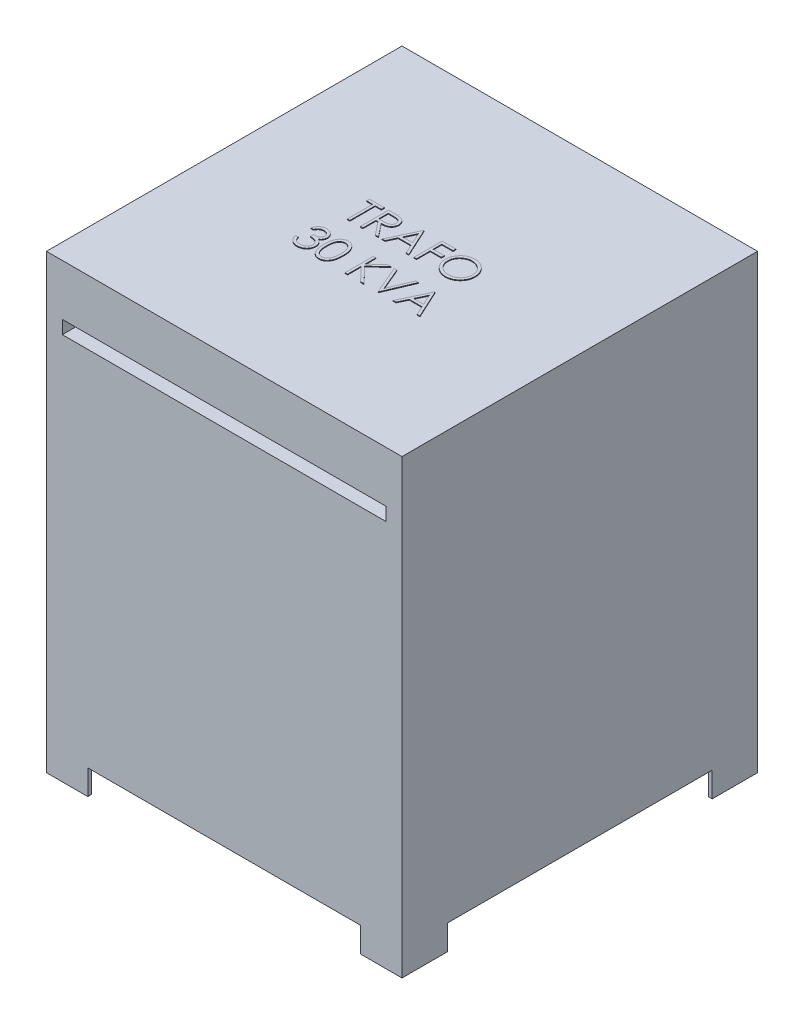
from build123d import *

# Parameters (mm, degrees)
CROQUIS1_W              = 500
CROQUIS1_H              = 500
SALIENTE_EXTRUIR1_DEPTH = 600
CROQUIS2_W              = 455.22672881
CROQUIS2_H              = 18.63501229
CORTAR_EXTRUIR1_DEPTH   = 20
SALIENTE_EXTRUIR2_DEPTH = 35
SALIENTE_EXTRUIR3_DEPTH = 1


with BuildPart() as part:
    # Croquis1 → Saliente-Extruir1 (new body)
    with BuildSketch(Plane(origin=(0, 0, 0), x_dir=(1, 0, 0), z_dir=(0, 1, 0))):
        with Locations((250, -250)):
            Rectangle(CROQUIS1_W, CROQUIS1_H)
    extrude(amount=SALIENTE_EXTRUIR1_DEPTH)

    # Croquis2 → Cortar-Extruir1 (cut)
    with BuildSketch(Plane.XY.offset(500)):
        with Locations((250, 518.961394413)):
            Rectangle(CROQUIS2_W, CROQUIS2_H)
    extrude(amount=-CORTAR_EXTRUIR1_DEPTH, mode=Mode.SUBTRACT)

    # Croquis3 → Saliente-Extruir2 (add)
    with BuildSketch(Plane.XZ):
        Polygon((500, 0), (500, 63.833187034), (495, 63.833187034), (495, 5), (441.775770603, 5), (441.775770603, 0), align=None)
        Polygon((58.224229397, 5), (58.224229397, 0), (0, 0), (0, 63.833187034), (5, 63.833187034), (5, 5), align=None)
        Polygon((441.775770603, 495), (441.775770603, 500), (500, 500), (500, 436.166812966), (495, 436.166812966), (495, 495), align=None)
        Polygon((0, 500), (0, 436.166812966), (5, 436.166812966), (5, 495), (58.224229397, 495), (58.224229397, 500), align=None)
    extrude(amount=SALIENTE_EXTRUIR2_DEPTH)

    # Croquis4 → Saliente-Extruir3 (add)
    with BuildSketch(Plane(origin=(0, 600, 0), x_dir=(1, 0, 0), z_dir=(0, 1, 0))):
        Polygon((164.519230769, -214.383012821), (164.519230769, -210.3125), (185.380608974, -210.3125), (185.380608974, -214.383012821), (176.730769231, -214.383012821), (176.730769231, -250), (173.169070513, -250), (173.169070513, -214.383012821), align=None)
        with BuildLine():
            Line((191.486378205, -210.3125), (199.428648337, -210.3125))
            add(Edge.make_bspline(
                [(199.428648337, -210.3125), (199.958659348, -210.314264234), (200.9763392, -210.317651759), (202.434268248, -210.33654032), (203.75900408, -210.390678104), (204.949854044, -210.437266506), (206.006796292, -210.522219769), (206.933071821, -210.603416392), (207.724414462, -210.70970701), (208.20345224, -210.808420288), (208.420347556, -210.853114984)],
                knots=[0, 0, 0, 0, 0.001590064, 0.003053099, 0.004373697, 0.005567528, 0.006627892, 0.007554255, 0.00835703, 0.009021242, 0.009021242, 0.009021242, 0.009021242], degree=3))
            add(Edge.make_bspline(
                [(208.420347556, -210.853114984), (208.710708383, -210.924855984), (209.285235853, -211.066807554), (210.112437495, -211.366840528), (210.900680275, -211.7140452), (211.646689891, -212.1218481), (212.346729666, -212.593276405), (213.008017654, -213.120191722), (213.633554605, -213.69971093), (214.198042733, -214.346445294), (214.730298051, -215.024948573), (215.179204798, -215.758642959), (215.566174702, -216.525876351), (215.874268957, -217.334451535), (216.122349549, -218.176526983), (216.297272085, -219.059730303), (216.402173945, -219.980037789), (216.412853914, -220.607756933), (216.418269231, -220.926044171)],
                knots=[0, 0, 0, 0, 0.00089672, 0.001774311, 0.002635617, 0.003478865, 0.004321176, 0.005164237, 0.006013572, 0.006875172, 0.007737029, 0.008597454, 0.009450761, 0.010311517, 0.01118954, 0.012081383, 0.013009382, 0.013963938, 0.013963938, 0.013963938, 0.013963938], degree=3))
            add(Edge.make_bspline(
                [(216.418269231, -220.926044171), (216.401611842, -221.454852946), (216.369108961, -222.486695832), (216.066065374, -223.984171898), (215.56967091, -225.381050734), (214.8856479, -226.675573503), (214.014569917, -227.842506714), (212.967672732, -228.867469912), (211.744372316, -229.725172492), (210.605575608, -230.319949832), (209.599619951, -230.70086942), (208.771474351, -230.968888847), (207.868107731, -231.175966489), (206.898175455, -231.361478697), (205.857641147, -231.501538089), (204.748998736, -231.604120009), (203.571457552, -231.668232882), (202.762523462, -231.677780616), (202.346379207, -231.682692308)],
                knots=[0, 0, 0, 0, 0.001584968, 0.003092683, 0.004561215, 0.006019382, 0.007467916, 0.008912779, 0.010395192, 0.011934848, 0.012752794, 0.013620243, 0.014543906, 0.015530919, 0.016582184, 0.017692087, 0.018870437, 0.020118849, 0.020118849, 0.020118849, 0.020118849], degree=3))
            Line((202.346379207, -231.682692308), (216.927083333, -250))
            Line((216.927083333, -250), (212.522661258, -250))
            Line((212.522661258, -250), (197.941957131, -231.682692308))
            Line((197.941957131, -231.682692308), (195.048076923, -231.682692308))
            Line((195.048076923, -231.682692308), (195.048076923, -250))
            Line((195.048076923, -250), (191.486378205, -250))
            Line((191.486378205, -250), (191.486378205, -210.3125))
        make_face()
        with BuildLine():
            Line((195.048076923, -214.383012821), (195.048076923, -227.612179487))
            Line((195.048076923, -227.612179487), (202.314578325, -227.66783103))
            add(Edge.make_bspline(
                [(202.314578325, -227.66783103), (202.653850195, -227.667981124), (203.311455709, -227.668272049), (204.262829319, -227.622985479), (205.148655585, -227.571467496), (205.965546257, -227.492666881), (206.713866263, -227.391111425), (207.393241574, -227.264077586), (208.00478118, -227.116076518), (208.718005678, -226.887004511), (209.514437775, -226.524079126), (210.379982008, -225.996059631), (211.117062087, -225.331927655), (211.739791419, -224.572496502), (212.240187651, -223.737514037), (212.592976124, -222.836989137), (212.816841318, -221.893655838), (212.84324536, -221.245296936), (212.856570513, -220.91809395)],
                knots=[0, 0, 0, 0, 0.001017659, 0.001972513, 0.002856741, 0.003679464, 0.004433898, 0.005121534, 0.005752062, 0.006320267, 0.007366438, 0.00837012, 0.009349902, 0.010327133, 0.011307463, 0.012256741, 0.013219111, 0.014199603, 0.014199603, 0.014199603, 0.014199603], degree=3))
            add(Edge.make_bspline(
                [(212.856570513, -220.91809395), (212.842939318, -220.598931909), (212.815927265, -219.966469202), (212.595392122, -219.040549505), (212.222450029, -218.166665339), (211.71986751, -217.348371625), (211.107555664, -216.60558337), (210.389576895, -215.970048688), (209.585562628, -215.445612794), (208.834094576, -215.110487229), (208.162420916, -214.905021036), (207.579245307, -214.760431947), (206.920302658, -214.644266987), (206.182393439, -214.551193439), (205.368667805, -214.471195411), (204.475011315, -214.417313635), (203.507353181, -214.385406426), (202.836669229, -214.383829257), (202.489483173, -214.383012821)],
                knots=[0, 0, 0, 0, 0.000956706, 0.001895842, 0.002836424, 0.003796329, 0.004767428, 0.005713537, 0.006661749, 0.007636875, 0.008169955, 0.008767704, 0.009438262, 0.010175878, 0.010998601, 0.011890763, 0.012861211, 0.01390272, 0.01390272, 0.01390272, 0.01390272], degree=3))
            Line((202.489483173, -214.383012821), (195.048076923, -214.383012821))
        make_face(mode=Mode.SUBTRACT)
        Polygon((241.350160256, -210.3125), (259.667467949, -250), (255.795710637, -250), (249.928448017, -237.279647436), (231.937099359, -237.279647436), (225.902882111, -250), (222.015224359, -250), (240.841346154, -210.3125), align=None)
        Polygon((241.056002103, -218.048064403), (233.869002905, -233.209134615), (248.052196014, -233.209134615), align=None, mode=Mode.SUBTRACT)
        Polygon((266.790865385, -210.3125), (286.125801282, -210.3125), (286.125801282, -214.383012821), (270.352564103, -214.383012821), (270.352564103, -226.594551282), (286.125801282, -226.594551282), (286.125801282, -230.665064103), (270.352564103, -230.665064103), (270.352564103, -250), (266.790865385, -250), align=None)
        with BuildLine():
            add(Edge.make_bspline(
                [(311.820913462, -209.294871795), (312.555791091, -209.313484998), (313.999151386, -209.350042866), (316.120447101, -209.629886272), (318.145587914, -210.114021498), (320.091070738, -210.758807103), (321.933625026, -211.618941651), (323.68711961, -212.658585744), (325.347382376, -213.888631303), (326.892035541, -215.299569858), (328.305556317, -216.834721522), (329.55090342, -218.472997824), (330.594597287, -220.204493172), (331.451686123, -222.024004376), (332.124090001, -223.927416513), (332.588082729, -225.92487708), (332.884470681, -228.003444012), (332.919121014, -229.421159353), (332.936698718, -230.140349559)],
                knots=[0, 0, 0, 0, 0.002204277, 0.004329381, 0.006404312, 0.008443246, 0.010467197, 0.012491945, 0.014549502, 0.016654434, 0.018758856, 0.020802078, 0.022817267, 0.024812408, 0.026826452, 0.028860869, 0.030955522, 0.033112143, 0.033112143, 0.033112143, 0.033112143], degree=3))
            add(Edge.make_bspline(
                [(332.936698718, -230.140349559), (332.91912359, -230.854242031), (332.884480977, -232.261406799), (332.587745732, -234.326783353), (332.122370107, -236.312186787), (331.457930303, -238.214302671), (330.60492711, -240.035137546), (329.554283652, -241.769900326), (328.31670028, -243.419159727), (326.908283308, -244.964847985), (325.372932207, -246.382230019), (323.726124717, -247.61729227), (322.004896893, -248.680056897), (320.18709931, -249.528050343), (318.296839963, -250.205821226), (316.317201121, -250.667926942), (314.257458946, -250.966003236), (312.852850242, -251.000231051), (312.138922276, -251.017628205)],
                knots=[0, 0, 0, 0, 0.002140736, 0.004219639, 0.006246322, 0.008250234, 0.01025257, 0.012267758, 0.014323686, 0.016428619, 0.018533041, 0.02058261, 0.022595131, 0.024590272, 0.026589321, 0.028608271, 0.030679299, 0.032820035, 0.032820035, 0.032820035, 0.032820035], degree=3))
            add(Edge.make_bspline(
                [(312.138922276, -251.017628205), (311.419735801, -251.000059265), (310.002027817, -250.965426207), (307.920848934, -250.668547778), (305.921985231, -250.204302636), (304.011152856, -249.540847422), (302.187286244, -248.683402038), (300.446818342, -247.637870239), (298.796735154, -246.397271406), (297.250717136, -244.989311141), (295.836150335, -243.456562292), (294.6028967, -241.814245293), (293.55712979, -240.09458074), (292.702563431, -238.292796315), (292.026011079, -236.417602277), (291.564447516, -234.456490077), (291.265816631, -232.420640323), (291.23140364, -231.034493173), (291.213942308, -230.331154848)],
                knots=[0, 0, 0, 0, 0.002156621, 0.004251274, 0.006293428, 0.00830485, 0.010307185, 0.012329184, 0.014385112, 0.016490044, 0.018594466, 0.020632903, 0.02264129, 0.02462206, 0.02660613, 0.028609617, 0.030657027, 0.032765994, 0.032765994, 0.032765994, 0.032765994], degree=3))
            add(Edge.make_bspline(
                [(291.213942308, -230.331154848), (291.220004692, -229.859070117), (291.232052982, -228.920856217), (291.377101638, -227.527636733), (291.587578071, -226.156823024), (291.889224758, -224.812313168), (292.283737411, -223.497398431), (292.749238078, -222.203010316), (293.317788111, -220.942266306), (293.960506173, -219.709193918), (294.677849889, -218.523014986), (295.470190977, -217.401791141), (296.309699173, -216.336113767), (297.230034083, -215.353598634), (298.200863416, -214.425663423), (299.237936097, -213.566568328), (300.334924047, -212.768566652), (301.49654746, -212.049425285), (302.694183255, -211.399013669), (303.928768146, -210.840873037), (305.183534627, -210.361832876), (306.464359652, -209.973566376), (307.767841979, -209.667042396), (309.0968265, -209.458316153), (310.450254459, -209.312897548), (311.362061379, -209.300906231), (311.820913462, -209.294871795)],
                knots=[0, 0, 0, 0, 0.001415697, 0.002813535, 0.004197719, 0.005574852, 0.00694326, 0.008313953, 0.009698342, 0.011088744, 0.012483572, 0.013853272, 0.015205394, 0.016549922, 0.017888301, 0.019231959, 0.020586859, 0.021954598, 0.023327663, 0.024672543, 0.026016201, 0.027354155, 0.02868479, 0.030029717, 0.031387996, 0.032763958, 0.032763958, 0.032763958, 0.032763958], degree=3))
        make_face()
        with BuildLine():
            add(Edge.make_bspline(
                [(311.995818309, -213.365384615), (311.61918809, -213.369975782), (310.869528261, -213.379114222), (309.755051823, -213.499488854), (308.655232573, -213.671050988), (307.569843377, -213.915770018), (306.503425632, -214.249190974), (305.44603904, -214.632922701), (304.40732584, -215.100340424), (303.39071513, -215.628441626), (302.40516026, -216.212969567), (301.475194806, -216.858988711), (300.598411254, -217.551349103), (299.776956355, -218.291666545), (299.013242171, -219.083711136), (298.292237074, -219.915475367), (297.642840925, -220.810733417), (297.047691973, -221.745208567), (296.515110213, -222.717683639), (296.041520923, -223.71792047), (295.654125466, -224.754078169), (295.338186021, -225.814915491), (295.076250666, -226.898752311), (294.910312419, -228.013810597), (294.788615129, -229.154487313), (294.779999024, -229.92535298), (294.775641026, -230.315254407)],
                knots=[0, 0, 0, 0, 0.001129379, 0.002247961, 0.003358946, 0.004467909, 0.00558199, 0.006708848, 0.007840575, 0.008996232, 0.010144261, 0.011275598, 0.012390586, 0.013493863, 0.014590216, 0.015689677, 0.016793241, 0.017904823, 0.019011389, 0.020117499, 0.021222007, 0.022326173, 0.02343693, 0.024563619, 0.025705936, 0.026875051, 0.026875051, 0.026875051, 0.026875051], degree=3))
            add(Edge.make_bspline(
                [(294.775641026, -230.315254407), (294.79009705, -230.888593875), (294.818536521, -232.016529977), (295.067519682, -233.669436609), (295.451036714, -235.257937713), (296.016383637, -236.773341506), (296.723395071, -238.228673998), (297.596824987, -239.611024828), (298.631637833, -240.9207676), (299.807108179, -242.148758597), (301.092106727, -243.269599413), (302.456593932, -244.253434493), (303.885951803, -245.08585429), (305.383907762, -245.764001093), (306.942464678, -246.30136687), (308.57166548, -246.669651347), (310.260657299, -246.912033743), (311.411942406, -246.935310529), (311.995818309, -246.947115385)],
                knots=[0, 0, 0, 0, 0.001719087, 0.003381976, 0.005003606, 0.006613403, 0.008224083, 0.009849704, 0.011508559, 0.013223615, 0.01494228, 0.016616929, 0.018262778, 0.019895847, 0.021542618, 0.023199204, 0.024900347, 0.026650858, 0.026650858, 0.026650858, 0.026650858], degree=3))
            add(Edge.make_bspline(
                [(311.995818309, -246.947115385), (312.388265337, -246.941723505), (313.16660566, -246.931029788), (314.324295958, -246.823321577), (315.461129787, -246.650603058), (316.575512604, -246.401925088), (317.666179661, -246.090693372), (318.737683232, -245.720945028), (319.778610274, -245.259649237), (320.802092364, -244.749971571), (321.781764033, -244.168944785), (322.716977658, -243.544851481), (323.584160644, -242.853510871), (324.405001007, -242.124192818), (325.171850695, -241.342192043), (325.879523998, -240.508525242), (326.525637997, -239.617930289), (327.120560954, -238.684872564), (327.651276523, -237.709736484), (328.113682378, -236.705873172), (328.50597762, -235.675754521), (328.822666916, -234.617894737), (329.070832419, -233.53430297), (329.241827939, -232.423528333), (329.361439699, -231.287792932), (329.370455306, -230.519625994), (329.375, -230.132399339)],
                knots=[0, 0, 0, 0, 0.001177062, 0.002334468, 0.003484725, 0.004624716, 0.005757169, 0.006886128, 0.008021925, 0.00917034, 0.010314315, 0.011436677, 0.012540499, 0.013638464, 0.014729123, 0.015823427, 0.016915881, 0.018027463, 0.019141004, 0.020243766, 0.021340839, 0.022445004, 0.023553967, 0.024672804, 0.025815121, 0.026976288, 0.026976288, 0.026976288, 0.026976288], degree=3))
            add(Edge.make_bspline(
                [(329.375, -230.132399339), (329.370451665, -229.747821746), (329.361429206, -228.984941248), (329.241885074, -227.857126612), (329.070651763, -226.75434466), (328.823878199, -225.680924751), (328.505809491, -224.636593262), (328.11361387, -223.622331033), (327.651137706, -222.634359535), (327.120365876, -221.675120632), (326.523740021, -220.754657085), (325.871796369, -219.874701157), (325.153278582, -219.051778108), (324.388715621, -218.265572203), (323.559010047, -217.53285149), (322.667920284, -216.853372908), (321.726264295, -216.210738458), (320.72923225, -215.631011105), (319.700260632, -215.095635431), (318.644414858, -214.636949949), (317.573656318, -214.247194666), (316.490707901, -213.914761223), (315.386454486, -213.672009453), (314.268357499, -213.499334245), (313.137963852, -213.379156119), (312.377741629, -213.369989684), (311.995818309, -213.365384615)],
                knots=[0, 0, 0, 0, 0.001153221, 0.002287625, 0.00339861, 0.004499823, 0.005588771, 0.006670994, 0.007759333, 0.008858938, 0.009957133, 0.011047908, 0.012141345, 0.013232004, 0.014335912, 0.015458555, 0.016591956, 0.017753668, 0.018916386, 0.020069936, 0.021204257, 0.022333552, 0.023465782, 0.024592471, 0.025726876, 0.026872149, 0.026872149, 0.026872149, 0.026872149], degree=3))
        make_face(mode=Mode.SUBTRACT)
        with BuildLine():
            Line((162.229567308, -286.616987179), (158.66786859, -286.616987179))
            add(Edge.make_bspline(
                [(158.66786859, -286.616987179), (158.764360816, -286.217475977), (158.952995227, -285.436464254), (159.346440926, -284.320596207), (159.77505748, -283.264641991), (160.289737505, -282.288374013), (160.851131415, -281.372172169), (161.494326561, -280.536816919), (162.189648415, -279.761062757), (162.958734893, -279.072618009), (163.76528311, -278.44920983), (164.620657816, -277.917680162), (165.507649557, -277.460433071), (166.432403832, -277.083739371), (167.397673815, -276.799967808), (168.394732937, -276.594082601), (169.426194054, -276.460379788), (170.126367626, -276.447330957), (170.481896034, -276.440705128)],
                knots=[0, 0, 0, 0, 0.001232182, 0.002408814, 0.003545696, 0.004648027, 0.005715757, 0.006765216, 0.007806452, 0.008836459, 0.009857312, 0.010860993, 0.01185302, 0.012848069, 0.01385172, 0.014866767, 0.015900204, 0.016966275, 0.016966275, 0.016966275, 0.016966275], degree=3))
            add(Edge.make_bspline(
                [(170.481896034, -276.440705128), (170.999905698, -276.456344614), (172.024625733, -276.487282443), (173.530063855, -276.769794357), (174.981796536, -277.216847197), (176.363933542, -277.834540353), (177.647749697, -278.596396493), (178.790026101, -279.503139492), (179.77527975, -280.537274428), (180.601849925, -281.679509756), (181.249039647, -282.900246335), (181.72626906, -284.156640975), (182.016800622, -285.445713329), (182.054453364, -286.316086048), (182.073317308, -286.752140925)],
                knots=[0, 0, 0, 0, 0.001552758, 0.003071645, 0.004577934, 0.006101164, 0.007602324, 0.009045087, 0.010462145, 0.011874334, 0.013261414, 0.014594825, 0.015896939, 0.01720426, 0.01720426, 0.01720426, 0.01720426], degree=3))
            add(Edge.make_bspline(
                [(182.073317308, -286.752140925), (182.060123016, -287.171771544), (182.034303836, -287.992923546), (181.815073424, -289.191729808), (181.446135444, -290.321594382), (180.935076529, -291.387273631), (180.273525021, -292.382010654), (179.472147119, -293.308043524), (178.525286579, -294.169479513), (177.807748622, -294.662959252), (177.438338842, -294.917017228)],
                knots=[0, 0, 0, 0, 0.001258171, 0.002462045, 0.003641173, 0.004814605, 0.005996491, 0.007214095, 0.008480478, 0.009824277, 0.009824277, 0.009824277, 0.009824277], degree=3))
            add(Edge.make_bspline(
                [(177.438338842, -294.917017228), (177.860520345, -295.120876851), (178.696984008, -295.524781728), (179.837155192, -296.316896121), (180.8721811, -297.231481488), (181.449392913, -297.945206213), (181.739408053, -298.303811098)],
                knots=[0, 0, 0, 0, 0.001404514, 0.002782748, 0.004150764, 0.005532205, 0.005532205, 0.005532205, 0.005532205], degree=3))
            add(Edge.make_bspline(
                [(181.739408053, -298.303811098), (181.930376846, -298.565269531), (182.309187185, -299.083904835), (182.776768684, -299.917755379), (183.200961319, -300.760848159), (183.531503985, -301.635780709), (183.78747551, -302.532412204), (183.97044659, -303.452282231), (184.084113188, -304.396141949), (184.100391322, -305.034685252), (184.108573718, -305.35565655)],
                knots=[0, 0, 0, 0, 0.000970448, 0.001925004, 0.002863669, 0.003799772, 0.004725827, 0.005658209, 0.00661081, 0.007573608, 0.007573608, 0.007573608, 0.007573608], degree=3))
            add(Edge.make_bspline(
                [(184.108573718, -305.35565655), (184.088225216, -305.911391782), (184.047623974, -307.020246946), (183.684720631, -308.658487093), (183.12214192, -310.259883413), (182.323210592, -311.791535608), (181.349534376, -313.224598857), (180.191143289, -314.506803433), (178.861199194, -315.608966178), (177.377956569, -316.529832157), (175.770985558, -317.265955025), (174.052226613, -317.776874243), (172.246444751, -318.109636918), (171.008112002, -318.145320163), (170.378543169, -318.163461538)],
                knots=[0, 0, 0, 0, 0.00166532, 0.003322802, 0.005010067, 0.006745256, 0.008489546, 0.010194993, 0.01191121, 0.013653959, 0.015418622, 0.017196718, 0.019021393, 0.020908428, 0.020908428, 0.020908428, 0.020908428], degree=3))
            add(Edge.make_bspline(
                [(170.378543169, -318.163461538), (169.954235032, -318.15361662), (169.119338108, -318.134245104), (167.891934153, -318.001818108), (166.720339884, -317.759951085), (165.60297123, -317.434476104), (164.538835549, -317.021819743), (163.531180071, -316.507938078), (162.573805385, -315.903423724), (161.67574585, -315.201141077), (160.83710852, -314.415540171), (160.080180307, -313.532674611), (159.392341584, -312.568864763), (158.792009877, -311.512915823), (158.251840861, -310.378474066), (157.807556799, -309.151013415), (157.416515083, -307.841507094), (157.234707051, -306.928947004), (157.141426282, -306.460737179)],
                knots=[0, 0, 0, 0, 0.001272929, 0.0025047, 0.003697472, 0.004857251, 0.005992575, 0.007116118, 0.008245385, 0.009384045, 0.010531358, 0.011686878, 0.012867078, 0.014078019, 0.015326305, 0.016631813, 0.017990347, 0.019421828, 0.019421828, 0.019421828, 0.019421828], degree=3))
            Line((157.141426282, -306.460737179), (160.703125, -306.460737179))
            add(Edge.make_bspline(
                [(160.703125, -306.460737179), (160.79591768, -306.766319741), (160.976407502, -307.360704365), (161.283637488, -308.216143546), (161.633661645, -309.000346471), (162.009157087, -309.7190658), (162.403519823, -310.37937965), (162.844787277, -310.963827629), (163.300276691, -311.498080368), (163.64362293, -311.799077307), (163.811661158, -311.946389223)],
                knots=[0, 0, 0, 0, 0.000958026, 0.001863444, 0.002724751, 0.003531963, 0.004295515, 0.005028532, 0.005727067, 0.006396634, 0.006396634, 0.006396634, 0.006396634], degree=3))
            add(Edge.make_bspline(
                [(163.811661158, -311.946389223), (164.033872338, -312.117706937), (164.477608783, -312.459813548), (165.200694975, -312.896394514), (165.96116288, -313.274684712), (166.775489989, -313.563651619), (167.626103904, -313.80832688), (168.526753492, -313.968443481), (169.469492829, -314.078300424), (170.113198719, -314.087994736), (170.442144932, -314.092948718)],
                knots=[0, 0, 0, 0, 0.000841147, 0.001679697, 0.002529479, 0.003384636, 0.004268112, 0.005181869, 0.006125671, 0.007112011, 0.007112011, 0.007112011, 0.007112011], degree=3))
            add(Edge.make_bspline(
                [(170.442144932, -314.092948718), (170.813546257, -314.085964792), (171.539789485, -314.072308329), (172.599500836, -313.946717724), (173.607647786, -313.763810358), (174.553037213, -313.481314928), (175.448052787, -313.132282058), (176.280148278, -312.694036747), (177.060246982, -312.179859992), (177.778357205, -311.595442747), (178.424078584, -310.955663294), (178.992624851, -310.28649722), (179.475958066, -309.590765939), (179.865843283, -308.864619389), (180.17371113, -308.111064562), (180.383297422, -307.327986764), (180.529024424, -306.521794549), (180.540892258, -305.973778562), (180.546875, -305.697516026)],
                knots=[0, 0, 0, 0, 0.00111374, 0.002177823, 0.003197561, 0.004183709, 0.005132987, 0.006075348, 0.006999251, 0.007931734, 0.008848081, 0.009722497, 0.010562704, 0.011384389, 0.012190465, 0.012998615, 0.013812882, 0.01464066, 0.01464066, 0.01464066, 0.01464066], degree=3))
            add(Edge.make_bspline(
                [(180.546875, -305.697516026), (180.529522474, -305.327726737), (180.494903765, -304.589988179), (180.230601123, -303.504619256), (179.795865788, -302.458871633), (179.187257847, -301.470587228), (178.446397353, -300.554646202), (177.580473855, -299.73740707), (176.582296623, -299.063058716), (175.663589179, -298.597142701), (174.849823565, -298.279222295), (174.153416974, -298.067461538), (173.373766204, -297.888145978), (172.520299569, -297.721319327), (171.586586311, -297.579336183), (170.573642952, -297.460933451), (169.481264227, -297.366193255), (168.725034042, -297.323885299), (168.335336538, -297.302083333)],
                knots=[0, 0, 0, 0, 0.001108536, 0.002211555, 0.003330702, 0.004493746, 0.005680755, 0.006856339, 0.008051546, 0.009281751, 0.009938739, 0.010670548, 0.011463102, 0.012337807, 0.013278926, 0.014295622, 0.015396893, 0.016567764, 0.016567764, 0.016567764, 0.016567764], degree=3))
            Line((168.335336538, -297.302083333), (168.335336538, -293.231570513))
            add(Edge.make_bspline(
                [(168.335336538, -293.231570513), (168.826340828, -293.223238363), (169.788097615, -293.20691773), (171.192970535, -293.009523326), (172.536373271, -292.736466204), (173.788533649, -292.318214471), (174.929818167, -291.832436105), (175.919960083, -291.267147657), (176.745087557, -290.638783983), (177.401190778, -289.937646359), (177.894781139, -289.185681088), (178.255674288, -288.401947559), (178.468856559, -287.579576511), (178.497314389, -287.01834233), (178.51161859, -286.736240485)],
                knots=[0, 0, 0, 0, 0.001471843, 0.002882979, 0.004248937, 0.005578907, 0.006835797, 0.007964896, 0.008990598, 0.009935638, 0.010830876, 0.011677677, 0.01251453, 0.013360286, 0.013360286, 0.013360286, 0.013360286], degree=3))
            add(Edge.make_bspline(
                [(178.51161859, -286.736240485), (178.506919465, -286.52898391), (178.497570781, -286.116656785), (178.379673077, -285.514256453), (178.202507612, -284.930272512), (177.958942825, -284.367188414), (177.632936107, -283.828909415), (177.242796796, -283.310846378), (176.778247801, -282.815957098), (176.245919965, -282.354671332), (175.674286105, -281.915055875), (175.04779312, -281.541838741), (174.385330791, -281.222693841), (173.686165687, -280.959514665), (172.94802887, -280.761538808), (172.174388439, -280.619391321), (171.363769171, -280.530517914), (170.810732567, -280.517722484), (170.529597356, -280.511217949)],
                knots=[0, 0, 0, 0, 0.000620932, 0.001235315, 0.001833856, 0.00244978, 0.003070152, 0.003717302, 0.004392275, 0.00510203, 0.005828682, 0.006552676, 0.007285176, 0.008032369, 0.008790314, 0.00957465, 0.010390275, 0.011233598, 0.011233598, 0.011233598, 0.011233598], degree=3))
            add(Edge.make_bspline(
                [(170.529597356, -280.511217949), (170.077707906, -280.526995), (169.19506271, -280.557811251), (167.922625705, -280.827720421), (166.739718972, -281.258364761), (165.835539449, -281.77240882), (165.167853117, -282.279846776), (164.690730692, -282.723013121), (164.222185619, -283.215510318), (163.793042676, -283.787672252), (163.359043119, -284.400751033), (162.963930681, -285.085912422), (162.579985956, -285.825283679), (162.348635616, -286.34797525), (162.229567308, -286.616987179)],
                knots=[0, 0, 0, 0, 0.001354364, 0.002645388, 0.003882969, 0.005118557, 0.005748233, 0.006395334, 0.007070307, 0.007784323, 0.008538548, 0.009322562, 0.010154605, 0.011036936, 0.011036936, 0.011036936, 0.011036936], degree=3))
        make_face()
        with BuildLine():
            add(Edge.make_bspline(
                [(187.670272436, -297.317983774), (187.673991928, -296.681879467), (187.681217094, -295.446237681), (187.761594724, -293.645733258), (187.895118695, -291.956629981), (188.078104976, -290.378847), (188.300785645, -288.911976991), (188.598050538, -287.559940013), (188.936106424, -286.316478402), (189.327906479, -285.177537317), (189.770000159, -284.127772292), (190.251174365, -283.147772241), (190.790525159, -282.239019973), (191.357227654, -281.387011099), (191.97422168, -280.605692417), (192.623949036, -279.884030083), (193.331768526, -279.238702824), (194.073618709, -278.650802788), (194.856216118, -278.135438243), (195.657253493, -277.681495582), (196.482244425, -277.293693515), (197.333441321, -276.98877518), (198.20319354, -276.736920043), (199.094541528, -276.564688226), (200.008956994, -276.45631971), (200.626170585, -276.44595937), (200.939190204, -276.440705128)],
                knots=[0, 0, 0, 0, 0.001908202, 0.00370671, 0.005405492, 0.00699022, 0.008471118, 0.009854296, 0.011140784, 0.012335038, 0.013464585, 0.014556113, 0.015607377, 0.016632709, 0.017623557, 0.018591527, 0.019542401, 0.020493508, 0.021428428, 0.022350448, 0.023253874, 0.024159292, 0.025060232, 0.025967672, 0.026879871, 0.027818536, 0.027818536, 0.027818536, 0.027818536], degree=3))
            add(Edge.make_bspline(
                [(200.939190204, -276.440705128), (201.254824648, -276.446236604), (201.882522249, -276.457236969), (202.810533647, -276.562963817), (203.71710593, -276.738395302), (204.59837411, -276.986963496), (205.461577082, -277.295343044), (206.299963133, -277.681866604), (207.118739862, -278.131796618), (207.904895801, -278.660478083), (208.667061529, -279.249919965), (209.386516109, -279.916246656), (210.063325029, -280.65273008), (210.70598251, -281.451490501), (211.2962558, -282.327848159), (211.858383111, -283.266560833), (212.361530304, -284.284044746), (212.846110996, -285.363323266), (213.264383078, -286.534259397), (213.641598538, -287.790252663), (213.946386842, -289.146138532), (214.200265198, -290.594803099), (214.396943929, -292.141566525), (214.540189067, -293.783113139), (214.615857085, -295.520522925), (214.630107179, -296.708402108), (214.637419872, -297.317983774)],
                knots=[0, 0, 0, 0, 0.000946611, 0.001882511, 0.002797753, 0.003713997, 0.004626888, 0.005544752, 0.006480652, 0.007426594, 0.00838396, 0.009368537, 0.010364347, 0.011382472, 0.012440927, 0.013531702, 0.01466234, 0.015844118, 0.017078964, 0.018389497, 0.019776144, 0.021245279, 0.022800376, 0.024452282, 0.026187252, 0.028016079, 0.028016079, 0.028016079, 0.028016079], degree=3))
            add(Edge.make_bspline(
                [(214.637419872, -297.317983774), (214.630031368, -297.924906659), (214.615635171, -299.107471149), (214.541037335, -300.837063458), (214.394095714, -302.469898413), (214.210286025, -304.00989205), (213.955708141, -305.450634692), (213.642685274, -306.79711192), (213.295132506, -308.055138447), (212.866112966, -309.214408186), (212.39654509, -310.291092901), (211.885651347, -311.296515029), (211.338305998, -312.239561384), (210.741987193, -313.112683514), (210.106381526, -313.9220665), (209.417885171, -314.653423472), (208.695906215, -315.324376627), (207.931497571, -315.921408474), (207.133080874, -316.443977241), (206.317116341, -316.911312866), (205.46912619, -317.28814789), (204.60832753, -317.611714872), (203.722407664, -317.858916425), (202.812470912, -318.02984318), (201.883145737, -318.14972039), (201.254931562, -318.158865296), (200.939190204, -318.163461538)],
                knots=[0, 0, 0, 0, 0.001820878, 0.003547907, 0.005191892, 0.006738103, 0.008199409, 0.009578308, 0.010884396, 0.012111773, 0.013283075, 0.014406619, 0.015493359, 0.016551814, 0.017576159, 0.018577381, 0.019561958, 0.020530483, 0.02148305, 0.022422826, 0.023347925, 0.024263548, 0.025179791, 0.026102839, 0.02703965, 0.027986261, 0.027986261, 0.027986261, 0.027986261], degree=3))
            add(Edge.make_bspline(
                [(200.939190204, -318.163461538), (200.626179269, -318.158173401), (200.008982801, -318.147746225), (199.094441905, -318.039867306), (198.206774912, -317.866427225), (197.341601541, -317.623578232), (196.494483022, -317.326320713), (195.676962628, -316.939042336), (194.879950501, -316.49302209), (194.105573035, -315.985074008), (193.368381566, -315.403122779), (192.664227738, -314.759456291), (192.010801182, -314.038012253), (191.402628848, -313.250182232), (190.824619098, -312.403214216), (190.292927097, -311.485544272), (189.801132591, -310.500811099), (189.351603723, -309.442652648), (188.953042985, -308.295628019), (188.600984152, -307.046615013), (188.323011117, -305.684589496), (188.085079391, -304.22049078), (187.893168976, -302.648027462), (187.76215118, -300.96634587), (187.681173769, -299.176493948), (187.673972524, -297.948792043), (187.670272436, -297.317983774)],
                knots=[0, 0, 0, 0, 0.000938665, 0.001850864, 0.002758304, 0.003649438, 0.004544677, 0.005448103, 0.006359297, 0.0072832, 0.008223144, 0.009174018, 0.010141988, 0.011139099, 0.012157844, 0.013215971, 0.014318159, 0.015458122, 0.016662495, 0.017958771, 0.019348059, 0.020830216, 0.022407989, 0.024098846, 0.025889411, 0.027781714, 0.027781714, 0.027781714, 0.027781714], degree=3))
        make_face()
        with BuildLine():
            add(Edge.make_bspline(
                [(191.231971154, -297.302083333), (191.233325598, -297.832180186), (191.235954309, -298.860994087), (191.304627298, -300.356002492), (191.398179035, -301.750398185), (191.518843745, -303.045951679), (191.698037893, -304.238277714), (191.898820219, -305.335576799), (192.143160164, -306.332041898), (192.432255456, -307.234510823), (192.761538072, -308.058299367), (193.121059919, -308.82484886), (193.507284188, -309.543214568), (193.939528127, -310.206943877), (194.410279291, -310.818201274), (194.90890464, -311.387805712), (195.454013408, -311.895771482), (196.208118345, -312.504995642), (197.203667654, -313.134542962), (198.458024601, -313.682753088), (199.746943644, -314.027268442), (200.621783712, -314.071080674), (201.05844351, -314.092948718)],
                knots=[0, 0, 0, 0, 0.001590124, 0.003086118, 0.004488605, 0.005782807, 0.006988098, 0.008104531, 0.009128413, 0.010063705, 0.010945069, 0.01178798, 0.012602674, 0.013389906, 0.014161118, 0.014915762, 0.015658161, 0.016393201, 0.017822473, 0.019175413, 0.020488548, 0.021797126, 0.021797126, 0.021797126, 0.021797126], degree=3))
            add(Edge.make_bspline(
                [(201.05844351, -314.092948718), (201.497927822, -314.074831025), (202.375989076, -314.038633045), (203.658845503, -313.689397362), (204.904242316, -313.162465977), (205.880236639, -312.539400514), (206.622761909, -311.946034635), (207.154767064, -311.440136391), (207.643059935, -310.873672539), (208.106179891, -310.262493022), (208.530939053, -309.594921104), (208.917190703, -308.874166902), (209.269653662, -308.098228902), (209.470461594, -307.556554182), (209.573129507, -307.279609876)],
                knots=[0, 0, 0, 0, 0.001315852, 0.002628986, 0.003961022, 0.005361638, 0.006085501, 0.00681089, 0.00756028, 0.008326683, 0.009109608, 0.009931294, 0.010778095, 0.011663965, 0.011663965, 0.011663965, 0.011663965], degree=3))
            add(Edge.make_bspline(
                [(209.573129507, -307.279609876), (209.692779017, -306.925486937), (209.935718835, -306.206465503), (210.248816632, -305.091091949), (210.495393927, -303.920846322), (210.71722852, -302.70272223), (210.868642636, -301.427736335), (210.990515162, -300.099833589), (211.06230063, -298.718012785), (211.071199147, -297.779176724), (211.075721154, -297.302083333)],
                knots=[0, 0, 0, 0, 0.001121291, 0.002276702, 0.003472754, 0.004707933, 0.005989868, 0.007322899, 0.008708087, 0.010139325, 0.010139325, 0.010139325, 0.010139325], degree=3))
            add(Edge.make_bspline(
                [(211.075721154, -297.302083333), (211.069482401, -296.825067109), (211.057278067, -295.891921401), (211.010628385, -294.525331317), (210.890164638, -293.227348671), (210.756371058, -291.992381704), (210.559098998, -290.827266665), (210.346398866, -289.72224981), (210.060635119, -288.691020868), (209.7553841, -287.71743454), (209.406016222, -286.812552118), (209.021436021, -285.97215472), (208.610707149, -285.192185073), (208.164594244, -284.474783146), (207.688393195, -283.816735561), (207.169535271, -283.231236141), (206.628601758, -282.700138377), (205.870942597, -282.093911031), (204.879046632, -281.475787341), (203.644814738, -280.906943457), (202.36040654, -280.580277996), (201.492118266, -280.534221366), (201.05844351, -280.511217949)],
                knots=[0, 0, 0, 0, 0.001431238, 0.002799808, 0.004100465, 0.005341031, 0.006525187, 0.007644673, 0.008715004, 0.009733284, 0.010704774, 0.011622637, 0.012504646, 0.013347369, 0.014155168, 0.014938214, 0.0156916, 0.01642664, 0.017844947, 0.019186557, 0.02049003, 0.021790687, 0.021790687, 0.021790687, 0.021790687], degree=3))
            add(Edge.make_bspline(
                [(201.05844351, -280.511217949), (200.619493046, -280.534253103), (199.740792455, -280.580365375), (198.443034397, -280.905726376), (197.19906541, -281.472837686), (196.209792394, -282.095958338), (195.451604814, -282.689437405), (194.917720702, -283.204087375), (194.417134642, -283.767040438), (193.955991971, -284.383919294), (193.524086706, -285.046874798), (193.12742701, -285.761122398), (192.770043004, -286.530281618), (192.440245138, -287.353700127), (192.150267988, -288.256091193), (191.911077512, -289.251328888), (191.690108249, -290.34513784), (191.533679754, -291.543921546), (191.394617523, -292.839799535), (191.305248667, -294.237676268), (191.235724587, -295.735192011), (191.233247357, -296.769325326), (191.231971154, -297.302083333)],
                knots=[0, 0, 0, 0, 0.0013165, 0.002635398, 0.003984267, 0.005402574, 0.006132654, 0.006869283, 0.007623927, 0.008390329, 0.009177562, 0.009996087, 0.010838998, 0.011720362, 0.012655654, 0.013679536, 0.014789667, 0.016001704, 0.017304618, 0.018699174, 0.020203111, 0.021801185, 0.021801185, 0.021801185, 0.021801185], degree=3))
        make_face(mode=Mode.SUBTRACT)
        Polygon((237.025240385, -277.458333333), (240.586939103, -277.458333333), (240.586939103, -292.571702224), (257.131347656, -277.458333333), (262.211538462, -277.458333333), (242.709647937, -295.266826923), (263.737980769, -317.145833333), (258.991699219, -317.145833333), (240.586939103, -297.993752504), (240.586939103, -317.145833333), (237.025240385, -317.145833333), align=None)
        Polygon((266.536458333, -277.458333333), (270.352564103, -277.458333333), (283.581730769, -308.7345002), (296.810897436, -277.458333333), (300.627003205, -277.458333333), (283.836137821, -317.145833333), (283.327323718, -317.145833333), align=None)
        Polygon((324.032451923, -277.458333333), (342.349759615, -317.145833333), (338.478002304, -317.145833333), (332.610739683, -304.425480769), (314.619391026, -304.425480769), (308.585173778, -317.145833333), (304.697516026, -317.145833333), (323.523637821, -277.458333333), align=None)
        Polygon((323.73829377, -285.193897736), (316.551294571, -300.354967949), (330.73448768, -300.354967949), align=None, mode=Mode.SUBTRACT)
    extrude(amount=SALIENTE_EXTRUIR3_DEPTH)


solid = part.part
